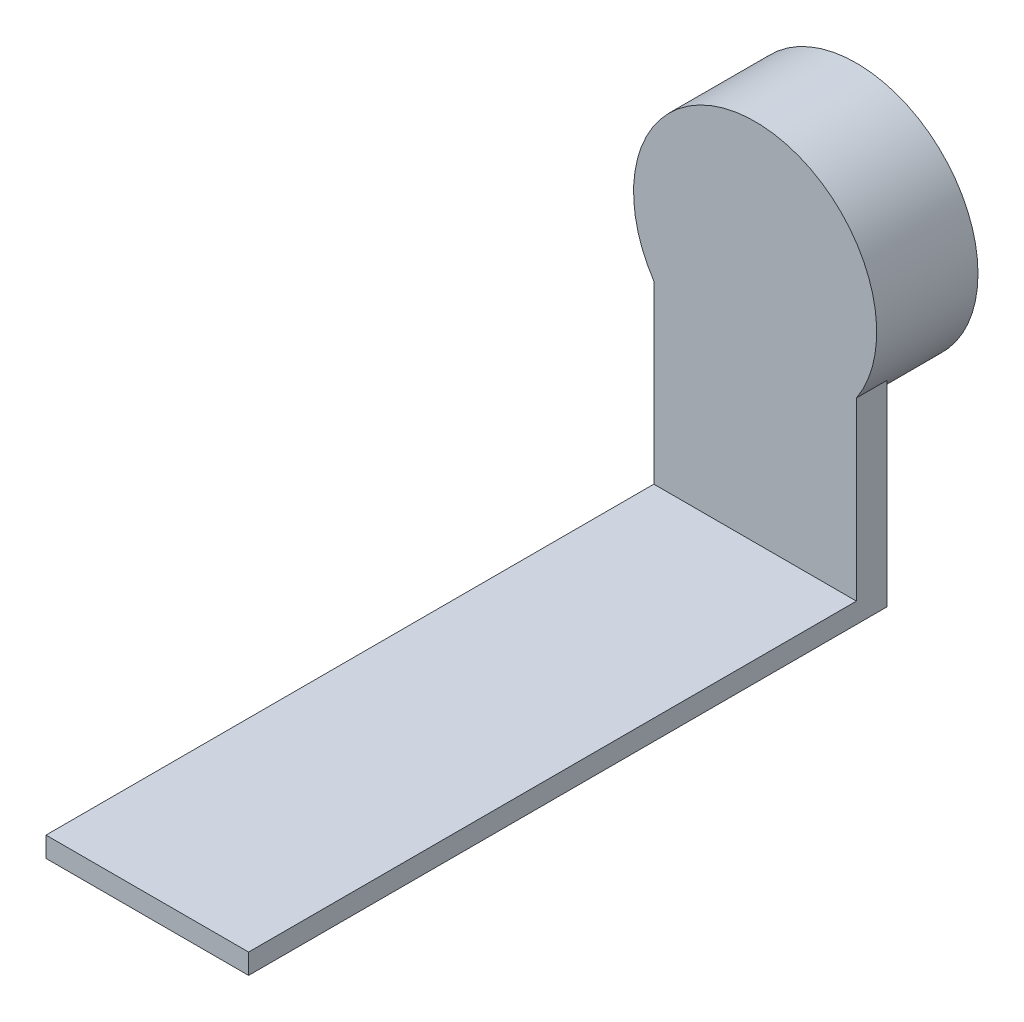
from build123d import *

# Parameters (mm, degrees)
SKETCH2_R           = 12
BOSS_EXTRUDE1_DEPTH = 10
BOSS_EXTRUDE2_DEPTH = 3
SKETCH4_W           = 20
SKETCH4_H           = 2
BOSS_EXTRUDE3_DEPTH = 60
SKETCH5_R           = 10
CUT_EXTRUDE1_DEPTH  = 8


with BuildPart() as part:
    # Sketch2 → Boss-Extrude1 (new body)
    with BuildSketch(Plane.XY):
        Circle(SKETCH2_R)
    extrude(amount=BOSS_EXTRUDE1_DEPTH)

    # Sketch3 → Boss-Extrude2 (add)
    with BuildSketch(Plane.XY.offset(10)):
        with BuildLine():
            Line((-10, -26), (-10, -6.633249581))
            ThreePointArc((-10, -6.633249581), (0, -12), (10, -6.633249581))
            Line((10, -6.633249581), (10, -26))
            Line((10, -26), (-10, -26))
        make_face()
    extrude(amount=-BOSS_EXTRUDE2_DEPTH)

    # Sketch4 → Boss-Extrude3 (add)
    with BuildSketch(Plane.XY.offset(10)):
        with Locations((0, -25)):
            Rectangle(SKETCH4_W, SKETCH4_H)
    extrude(amount=BOSS_EXTRUDE3_DEPTH)

    # Sketch5 → Cut-Extrude1 (cut)
    with BuildSketch(Plane(origin=(0, 0, 0), x_dir=(-1, 0, 0), z_dir=(0, 0, -1))):
        Circle(SKETCH5_R)
    extrude(amount=-CUT_EXTRUDE1_DEPTH, mode=Mode.SUBTRACT)


solid = part.part
